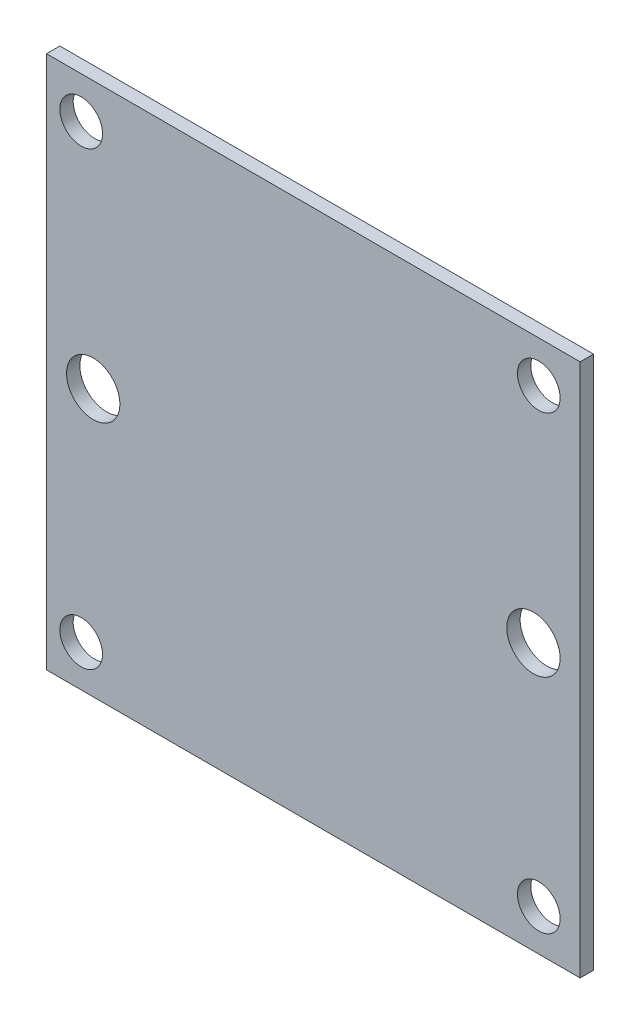
from build123d import *

# Parameters (mm, degrees)
SKETCH1_W           = 40
SKETCH1_H           = 40
BOSS_EXTRUDE1_DEPTH = 1
SKETCH2_R           = 1.6
SKETCH2_R_2         = 2
CUT_EXTRUDE1_DEPTH  = 10


with BuildPart() as part:
    # Sketch1 → Boss-Extrude1 (new body)
    with BuildSketch(Plane.XY):
        Rectangle(SKETCH1_W, SKETCH1_H)
    extrude(amount=BOSS_EXTRUDE1_DEPTH)

    # Sketch2 → Cut-Extrude1 (cut)
    with BuildSketch(Plane.XY.offset(1)):
        with Locations((-17.4, -16.9)):
            Circle(SKETCH2_R)
        with Locations((16.9, -16.9)):
            Circle(SKETCH2_R)
        with Locations((16.9, 16.9)):
            Circle(SKETCH2_R)
        with Locations((-17.4, 16.9)):
            Circle(SKETCH2_R)
        with Locations((16.5, 0)):
            Circle(SKETCH2_R_2)
        with Locations((-16.5, 0)):
            Circle(SKETCH2_R_2)
    extrude(amount=-CUT_EXTRUDE1_DEPTH, mode=Mode.SUBTRACT)


solid = part.part
